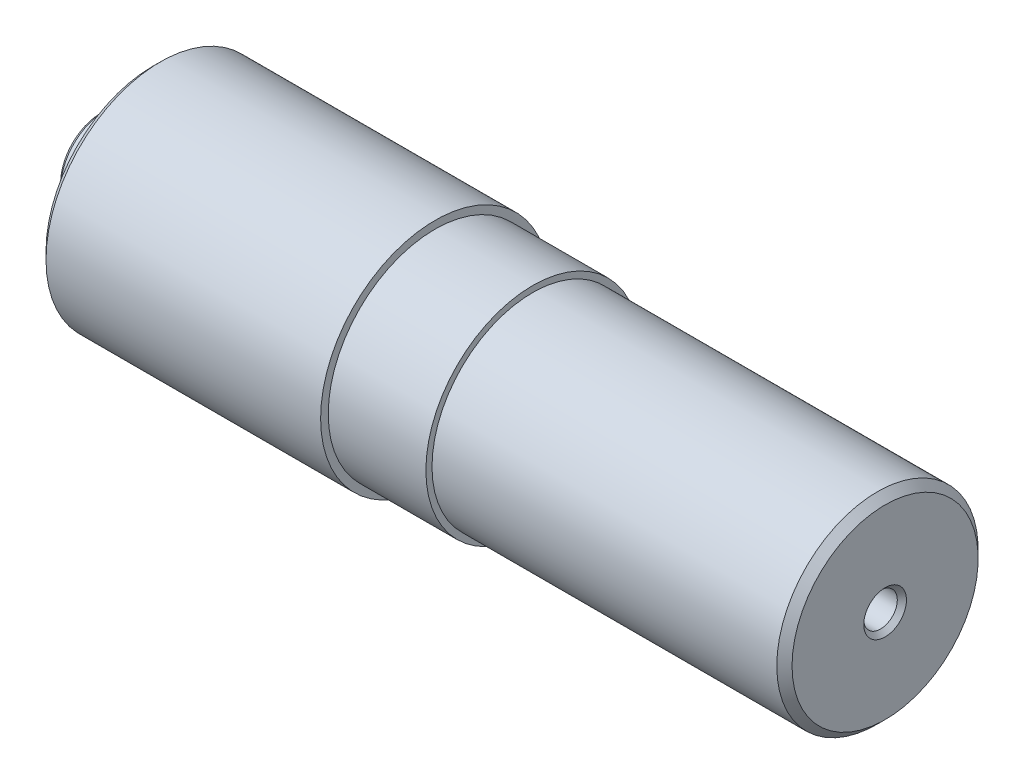
from build123d import *

# Parameters (mm, degrees)
CHAMFER1_SIZE                                        = 2.5
CHAMFER2_SIZE                                        = 1.5
CSK_FOR_M10_COUNTERSUNK_FLAT_HEAD_SCREW1_D           = 11
CSK_FOR_M10_COUNTERSUNK_FLAT_HEAD_SCREW1_DEPTH       = 10.695266595
CSK_FOR_M10_COUNTERSUNK_FLAT_HEAD_SCREW1_CSINK_D     = 14
CSK_FOR_M10_COUNTERSUNK_FLAT_HEAD_SCREW1_CSINK_ANGLE = 90
CSK_FOR_M10_COUNTERSUNK_FLAT_HEAD_SCREW1_TIP         = 3.304733405
CSK_FOR_M10_COUNTERSUNK_FLAT_HEAD_SCREW2_D           = 11
CSK_FOR_M10_COUNTERSUNK_FLAT_HEAD_SCREW2_DEPTH       = 10.695266595
CSK_FOR_M10_COUNTERSUNK_FLAT_HEAD_SCREW2_CSINK_D     = 14
CSK_FOR_M10_COUNTERSUNK_FLAT_HEAD_SCREW2_CSINK_ANGLE = 90
CSK_FOR_M10_COUNTERSUNK_FLAT_HEAD_SCREW2_TIP         = 3.304733405


with BuildPart() as part:
    # Sketch1 → Revolve1 (revolve)
    with BuildSketch(Plane.XY):
        Polygon((0, 0), (0, 14.7), (17, 14.7), (17, 37.5), (109.5, 37.5), (109.5, 35), (128.5, 35), (141.5, 35), (141.5, 33), (257, 33), (257, 0), align=None)
    revolve(axis=Axis((0, 0, 0), (1, 0, 0)))

    # Chamfer1
    chamfer1_edges = [part.edges().sort_by_distance(p)[0] for p in [
        (17, -37.5, 0),
        (257, -33, 0),
    ]]
    chamfer(chamfer1_edges, length=CHAMFER1_SIZE)

    # Chamfer2
    chamfer2_edges = [part.edges().sort_by_distance(p)[0] for p in [
        (0, -14.7, 0),
    ]]
    chamfer(chamfer2_edges, length=CHAMFER2_SIZE)

    # CSK for M10 Countersunk Flat Head Screw1
    with Locations(Plane.ZY):
        with Locations((0, 0)):
            CounterSinkHole(CSK_FOR_M10_COUNTERSUNK_FLAT_HEAD_SCREW1_D / 2, CSK_FOR_M10_COUNTERSUNK_FLAT_HEAD_SCREW1_CSINK_D / 2, depth=CSK_FOR_M10_COUNTERSUNK_FLAT_HEAD_SCREW1_DEPTH, counter_sink_angle=CSK_FOR_M10_COUNTERSUNK_FLAT_HEAD_SCREW1_CSINK_ANGLE)
            with Locations((0, 0, -(CSK_FOR_M10_COUNTERSUNK_FLAT_HEAD_SCREW1_DEPTH + CSK_FOR_M10_COUNTERSUNK_FLAT_HEAD_SCREW1_TIP / 2))):  # 118° drill point
                Cone(0, CSK_FOR_M10_COUNTERSUNK_FLAT_HEAD_SCREW1_D / 2, CSK_FOR_M10_COUNTERSUNK_FLAT_HEAD_SCREW1_TIP, mode=Mode.SUBTRACT)

    # CSK for M10 Countersunk Flat Head Screw2
    with Locations(Plane(origin=(257, 0, 0), x_dir=(0, 0, -1), z_dir=(1, 0, 0))):
        with Locations((0, 0)):
            CounterSinkHole(CSK_FOR_M10_COUNTERSUNK_FLAT_HEAD_SCREW2_D / 2, CSK_FOR_M10_COUNTERSUNK_FLAT_HEAD_SCREW2_CSINK_D / 2, depth=CSK_FOR_M10_COUNTERSUNK_FLAT_HEAD_SCREW2_DEPTH, counter_sink_angle=CSK_FOR_M10_COUNTERSUNK_FLAT_HEAD_SCREW2_CSINK_ANGLE)
            with Locations((0, 0, -(CSK_FOR_M10_COUNTERSUNK_FLAT_HEAD_SCREW2_DEPTH + CSK_FOR_M10_COUNTERSUNK_FLAT_HEAD_SCREW2_TIP / 2))):  # 118° drill point
                Cone(0, CSK_FOR_M10_COUNTERSUNK_FLAT_HEAD_SCREW2_D / 2, CSK_FOR_M10_COUNTERSUNK_FLAT_HEAD_SCREW2_TIP, mode=Mode.SUBTRACT)


solid = part.part
